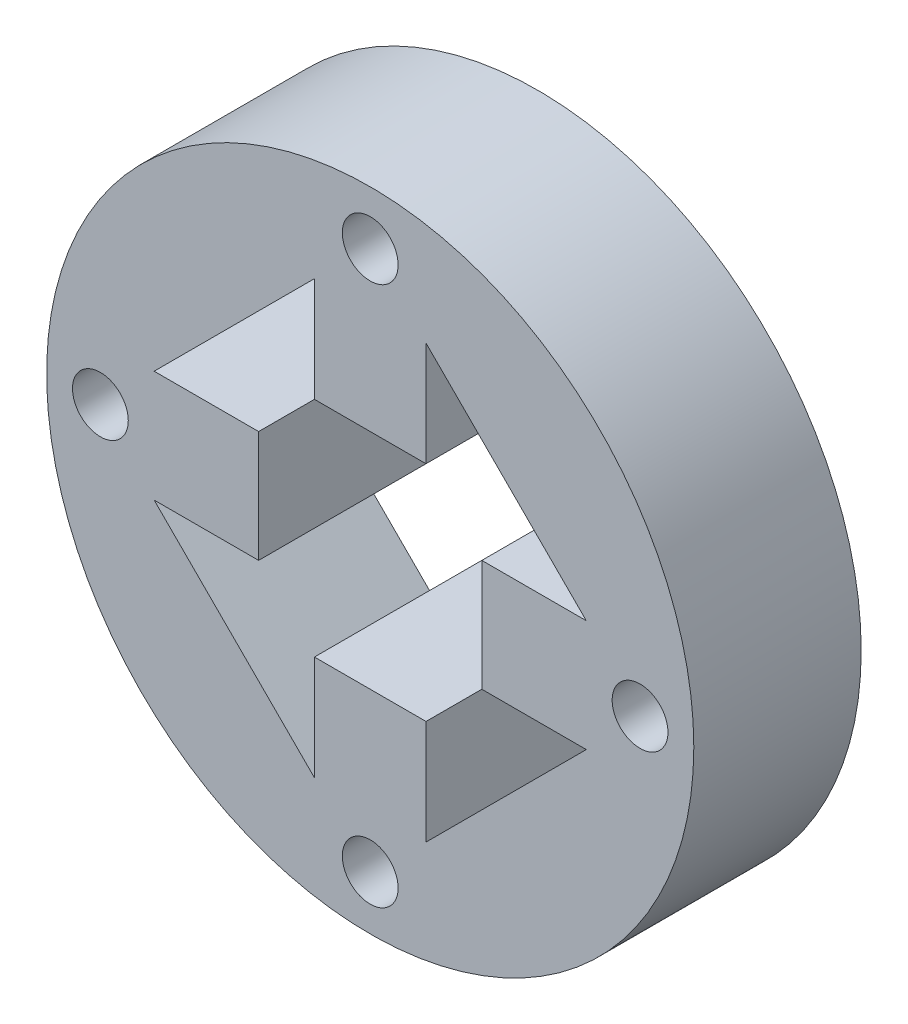
from build123d import *

# Parameters (mm, degrees)
SKETCH6_R                 = 29
SKETCH6_R_2               = 20
INNER_RING_DEPTH          = 15
MOTOR_CONNECTOR_CUT_DEPTH = 15
SKETCH8_R                 = 2.5
M3_HOLES_DEPTH            = 38
M3_HOLES_DEPTH_BACK       = 53
BOSS_EXTRUDE1_DEPTH       = 15


with BuildPart() as part:
    # Sketch6 → Inner Ring (new body)
    with BuildSketch(Plane.XY):
        Circle(SKETCH6_R)
        Circle(SKETCH6_R_2, mode=Mode.SUBTRACT)
    extrude(amount=-INNER_RING_DEPTH)

    # Sketch7 → Motor Connector Cut (add)
    with BuildSketch(Plane.XY):
        with BuildLine():
            ThreePointArc((20, 0), (19.840593925, 2.52008585), (19.364916731, 5))
            Line((19.364916731, 5), (9.999996731, 5))
            Line((9.999996731, 5), (9.999996731, -5))
            Line((9.999996731, -5), (19.364916731, -5))
            ThreePointArc((19.364916731, -5), (19.840593925, -2.52008585), (20, 0))
        make_face()
        with BuildLine():
            ThreePointArc((5, 19.364916731), (0, 20), (-5, 19.364916731))
            Line((-5, 19.364916731), (-5, 9.999996731))
            Line((-5, 9.999996731), (5, 9.999996731))
            Line((5, 9.999996731), (5, 19.364916731))
        make_face()
        with BuildLine():
            Line((-9.999996731, -5), (-9.999996731, 5))
            Line((-9.999996731, 5), (-19.364916731, 5))
            ThreePointArc((-19.364916731, 5), (-20, 0), (-19.364916731, -5))
            Line((-19.364916731, -5), (-9.999996731, -5))
        make_face()
        with BuildLine():
            Line((-5, -9.999996731), (-5, -19.364916731))
            ThreePointArc((-5, -19.364916731), (0, -20), (5, -19.364916731))
            Line((5, -19.364916731), (5, -9.999996731))
            Line((5, -9.999996731), (-5, -9.999996731))
        make_face()
    extrude(amount=-MOTOR_CONNECTOR_CUT_DEPTH)

    # Sketch8 → M3 Holes (cut, two sides)
    with BuildSketch(Plane.XY) as m3_holes_sk:
        with Locations((0, 24.182458366)):
            Circle(SKETCH8_R)
        with Locations((24.182458366, 0)):
            Circle(SKETCH8_R)
        with Locations((0, -24.182458366)):
            Circle(SKETCH8_R)
        with Locations((-24.182458366, 0)):
            Circle(SKETCH8_R)
    extrude(amount=M3_HOLES_DEPTH, mode=Mode.SUBTRACT)
    extrude(m3_holes_sk.sketch, amount=-M3_HOLES_DEPTH_BACK, mode=Mode.SUBTRACT)

    # Sketch9 → Boss-Extrude1 (add)
    with BuildSketch(Plane(origin=(0, 0, -15), x_dir=(-1, 0, 0), z_dir=(0, 0, -1))):
        with BuildLine():
            Line((-19.364916731, 5), (-5, 19.364916731))
            ThreePointArc((-5, 19.364916731), (-14.142135624, 14.142135624), (-19.364916731, 5))
        make_face()
        with BuildLine():
            Line((5, 19.364916731), (19.364916731, 5))
            ThreePointArc((19.364916731, 5), (14.142135624, 14.142135624), (5, 19.364916731))
        make_face()
        with BuildLine():
            Line((19.364916731, -5), (5, -19.364916731))
            ThreePointArc((5, -19.364916731), (14.142135624, -14.142135624), (19.364916731, -5))
        make_face()
        with BuildLine():
            Line((-5, -19.364916731), (-19.364916731, -5))
            ThreePointArc((-19.364916731, -5), (-14.142135624, -14.142135624), (-5, -19.364916731))
        make_face()
    extrude(amount=-BOSS_EXTRUDE1_DEPTH)


solid = part.part
